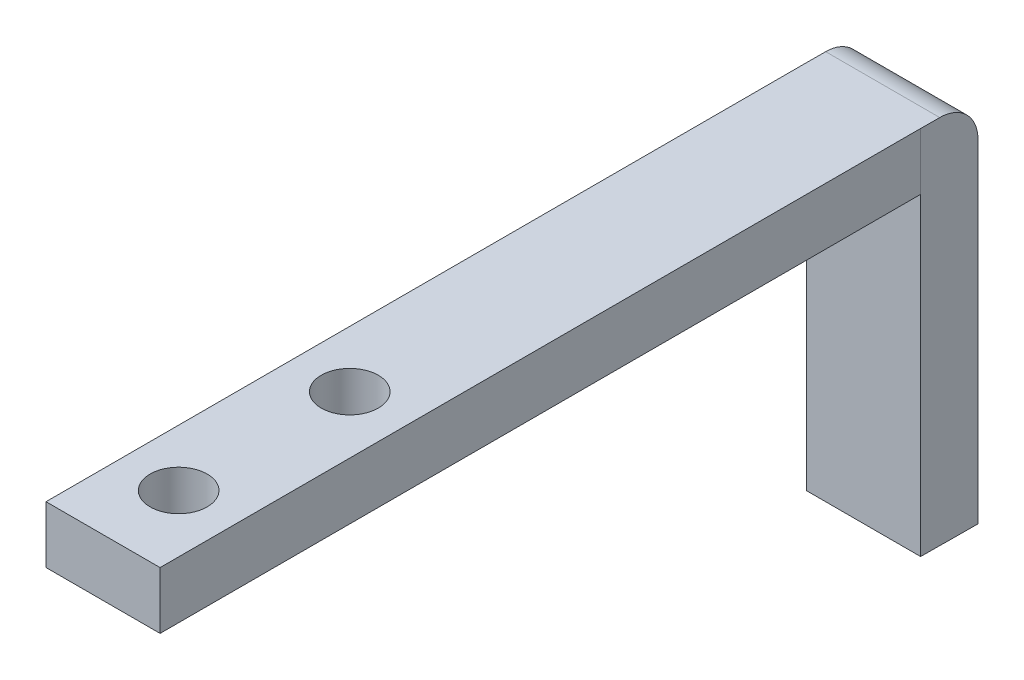
from build123d import *

# Parameters (mm, degrees)
BOSS_EXTRUDE1_DEPTH = 19.5
SKETCH5_W           = 6.000098135
SKETCH5_H           = 3
BOSS_EXTRUDE2_DEPTH = 40
FILLET1_R           = 2
SKETCH6_R           = 1.5
CUT_EXTRUDE1_DEPTH  = 4


with BuildPart() as part:
    # Sketch3 → Boss-Extrude1 (new body)
    with BuildSketch(Plane.XZ.offset(9.5)):
        Polygon((20.540895742, -1), (26.540993877, -1), (26.523835555, 2), (20.52373742, 2), align=None)
    extrude(amount=-BOSS_EXTRUDE1_DEPTH)

    # Sketch5 → Boss-Extrude2 (add)
    with BuildSketch(Plane.XY.offset(2)):
        with Locations((23.523786488, 8.5)):
            Rectangle(SKETCH5_W, SKETCH5_H)
    extrude(amount=BOSS_EXTRUDE2_DEPTH)

    # Fillet1
    fillet1_edges = [part.edges().sort_by_distance(p)[0] for p in [
        (23.540944809, 10, -1),
    ]]
    fillet(fillet1_edges, radius=FILLET1_R)

    # Sketch6 → Cut-Extrude1 (cut, through all)
    with BuildSketch(Plane.XZ.offset(-7)):
        with Locations((23.5, 38)):
            Circle(SKETCH6_R)
        with Locations((23.5, 29)):
            Circle(SKETCH6_R)
    extrude(amount=-CUT_EXTRUDE1_DEPTH, mode=Mode.SUBTRACT)


solid = part.part
